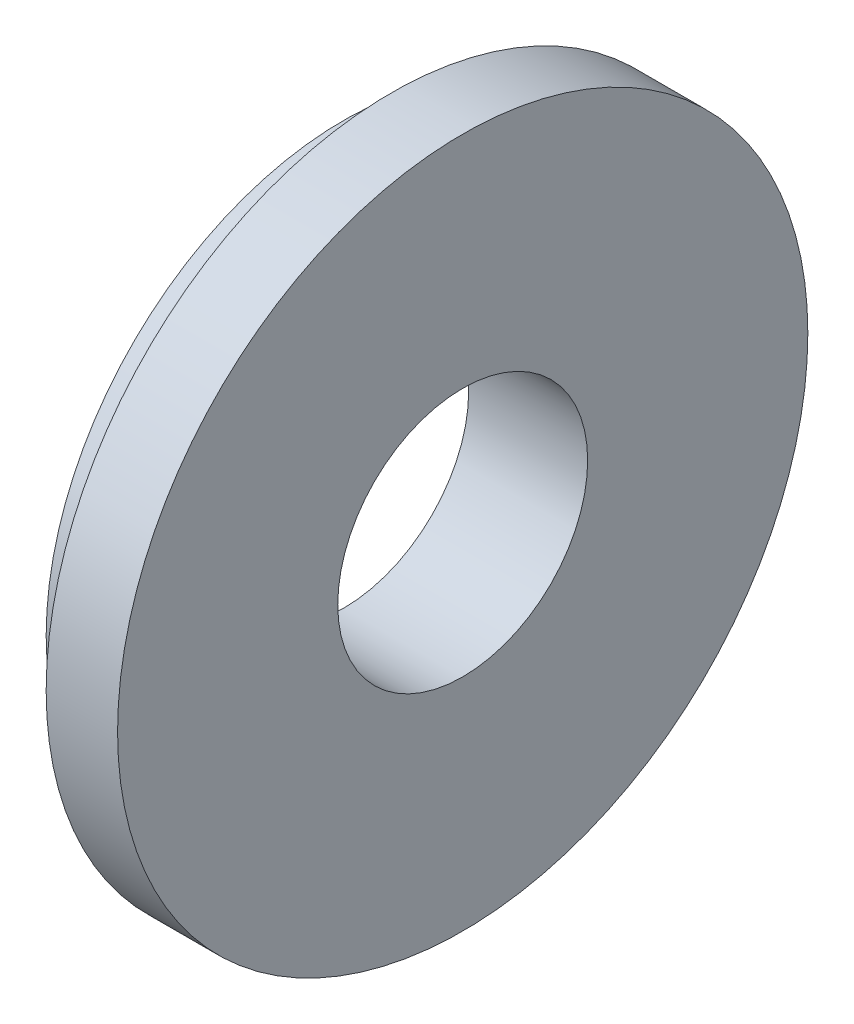
from build123d import *

# Parameters (mm, degrees)
SKETCH_2_R          = 5.25
CUT_EXTRUDE_1_DEPTH = 6


with BuildPart() as part:
    # Эскиз1 → Повернуть1 (revolve)
    with BuildSketch(Plane.XY):
        Polygon((0, 0), (0, 12.5), (2, 12.5), (2, 14.5), (5, 14.5), (5, 0), align=None)
    revolve(axis=Axis((-1000, 0, 0), (1, 0, 0)))

    # Эскиз2 → Вырез-Вытянуть1 (cut, through all)
    with BuildSketch(Plane(origin=(5, 0, 0), x_dir=(0, 0, -1), z_dir=(1, 0, 0))):
        Circle(SKETCH_2_R)
    extrude(amount=-CUT_EXTRUDE_1_DEPTH, mode=Mode.SUBTRACT)


solid = part.part
